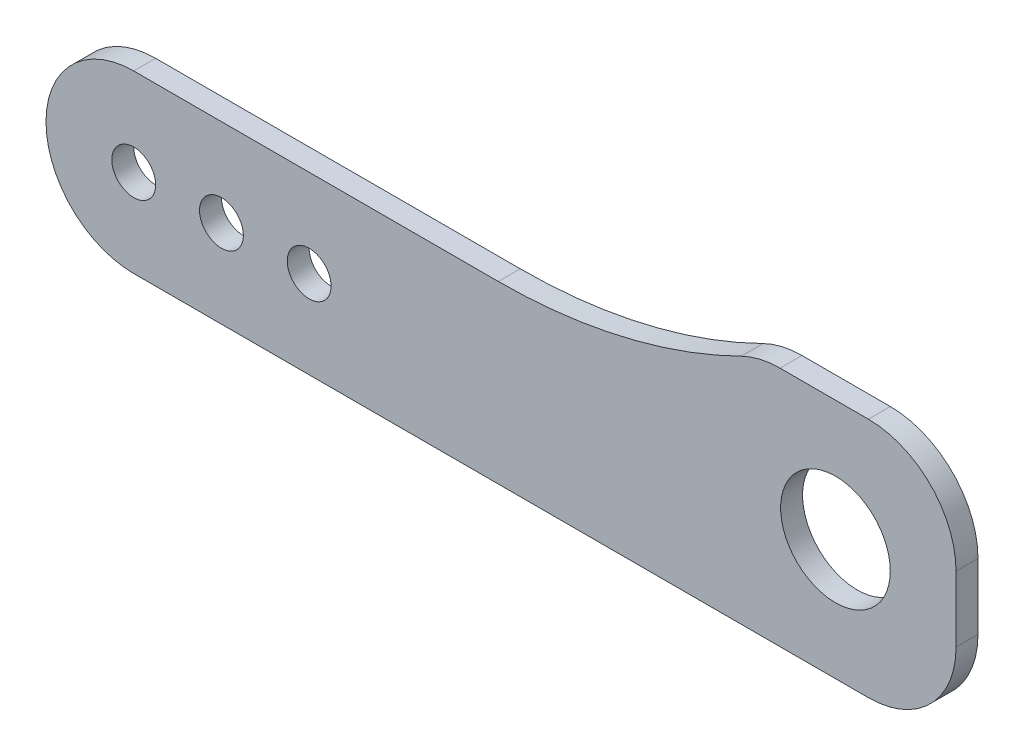
from build123d import *

# Parameters (mm, degrees)
BOSS_EXTRUDE1_DEPTH = 2
SKETCH2_R           = 2
CUT_EXTRUDE1_DEPTH  = 2
SKETCH3_R           = 5
CUT_EXTRUDE2_DEPTH  = 2


with BuildPart() as part:
    # Sketch1 → Boss-Extrude1 (new body)
    with BuildSketch(Plane.XY):
        with BuildLine():
            Line((0, 8), (33.251315826, 8))
            ThreePointArc((33.251315826, 8), (44.62278648, 9.310271564), (55.398268548, 13.172413793))
            ThreePointArc((55.398268548, 13.172413793), (57.122345679, 13.79035655), (58.941780983, 14))
            Line((58.941780983, 14), (67, 14))
            ThreePointArc((67, 14), (72.656854249, 11.656854249), (75, 6))
            Line((75, 6), (75, 0))
            ThreePointArc((75, 0), (72.656854249, -5.656854249), (67, -8))
            Line((67, -8), (0, -8))
            ThreePointArc((0, -8), (-8, 0), (0, 8))
        make_face()
    extrude(amount=BOSS_EXTRUDE1_DEPTH)

    # Sketch2 → Cut-Extrude1 (cut)
    with BuildSketch(Plane.XY.offset(2)):
        Circle(SKETCH2_R)
        with Locations((8, 0)):
            Circle(SKETCH2_R)
        with Locations((16, 0)):
            Circle(SKETCH2_R)
    extrude(amount=-CUT_EXTRUDE1_DEPTH, mode=Mode.SUBTRACT)

    # Sketch3 → Cut-Extrude2 (cut)
    with BuildSketch(Plane.XY.offset(2)):
        with Locations((64, 3)):
            Circle(SKETCH3_R)
    extrude(amount=-CUT_EXTRUDE2_DEPTH, mode=Mode.SUBTRACT)


solid = part.part
